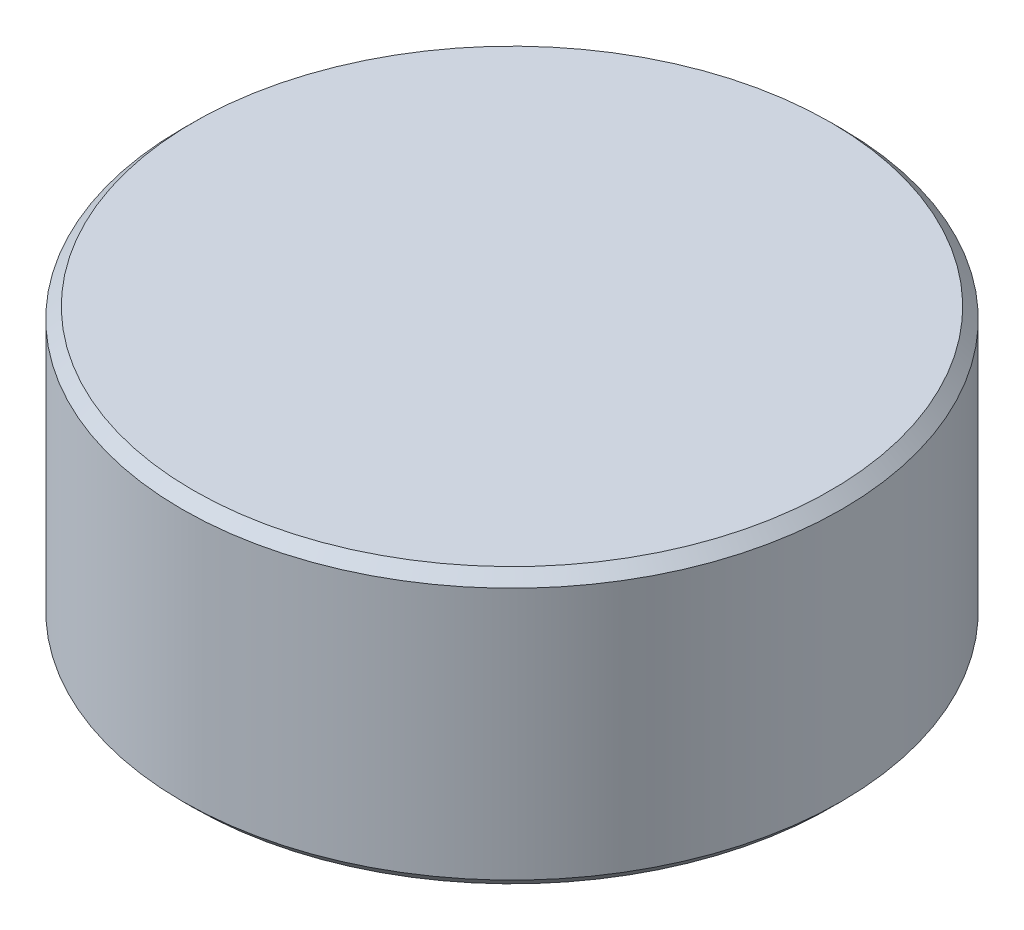
from build123d import *

# Parameters (mm, degrees)
SKETCH1_R           = 3
BOSS_EXTRUDE1_DEPTH = 1.25
CHAMFER1_SIZE       = 0.1


with BuildPart() as part:
    # Sketch1 → Boss-Extrude1 (new, symmetric)
    with BuildSketch(Plane(origin=(0, 0, 0), x_dir=(1, 0, 0), z_dir=(0, 1, 0))):
        Circle(SKETCH1_R)
    extrude(amount=BOSS_EXTRUDE1_DEPTH, both=True)

    # Chamfer1
    chamfer1_edges = [part.edges().sort_by_distance(p)[0] for p in [
        (-3, -1.25, 0),
        (-3, 1.25, 0),
    ]]
    chamfer(chamfer1_edges, length=CHAMFER1_SIZE)


solid = part.part
